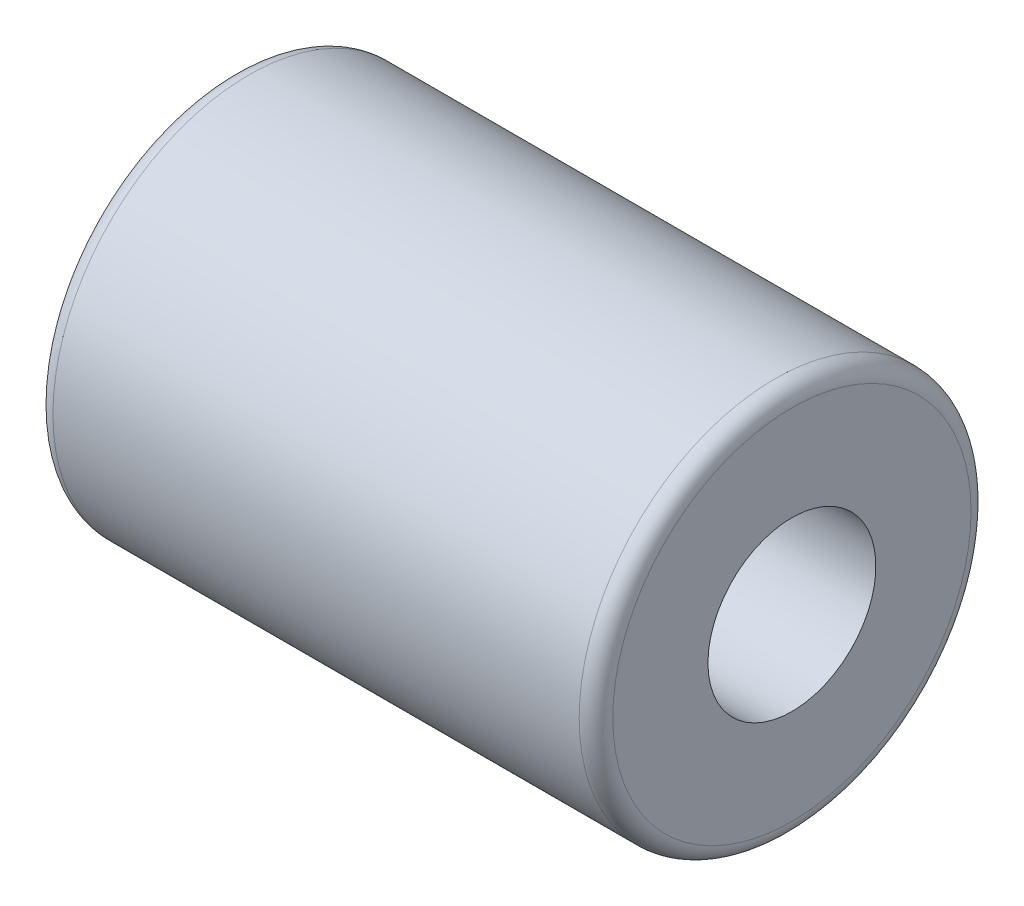
from build123d import *

# Parameters (mm, degrees)
SKETCH1_W = 10
SKETCH1_H = 2
FILLET1_R = 0.3


with BuildPart() as part:
    # Sketch1 → Revolve1 (revolve)
    with BuildSketch(Plane.XY):
        with Locations((5, 2.5)):
            Rectangle(SKETCH1_W, SKETCH1_H)
    revolve(axis=Axis((0, 0, 0), (1, 0, 0)))

    # Fillet1
    fillet1_edges = [part.edges().sort_by_distance(p)[0] for p in [
        (0, -3.5, 0),
        (10, -3.5, 0),
    ]]
    fillet(fillet1_edges, radius=FILLET1_R)


solid = part.part
